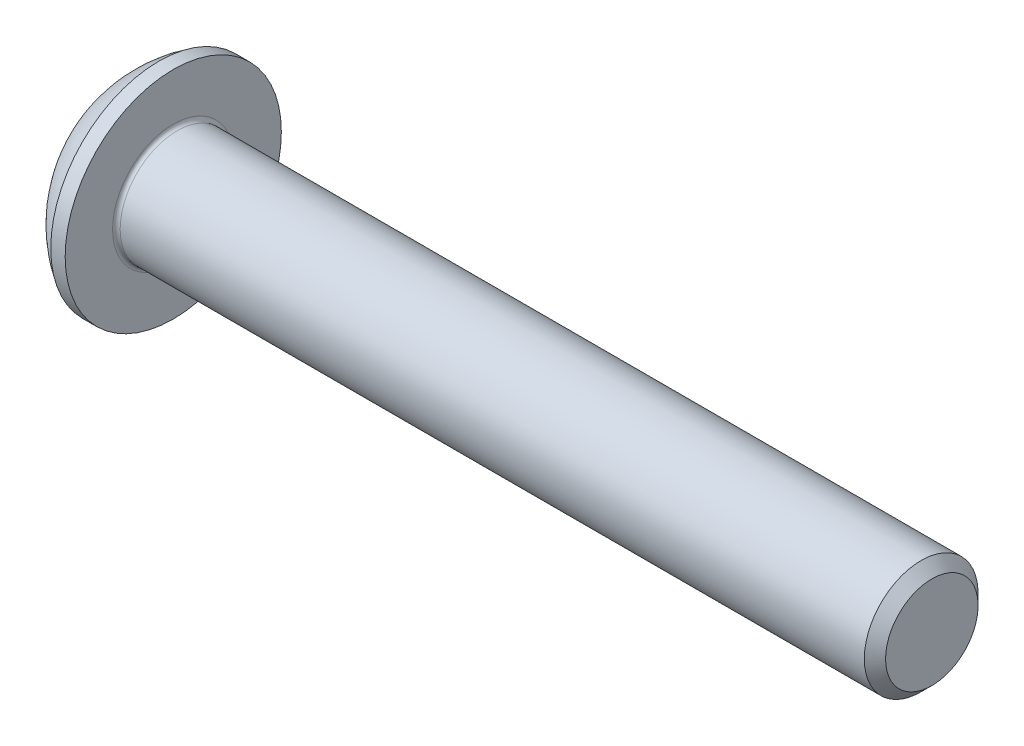
from build123d import *

# Parameters (mm, degrees)
FILLET1_R   = 0.1
HEX_2_DEPTH = 1.04


with BuildPart() as part:
    # BodySke → BaseBody (revolve)
    with BuildSketch(Plane.XY):
        with BuildLine():
            Line((21.65, 0), (21.65, 1.2195))
            Line((21.65, 1.2195), (21.3695, 1.5))
            Line((21.3695, 1.5), (1.65, 1.5))
            Line((1.65, 1.5), (1.65, 2.85))
            Line((1.65, 2.85), (1.27, 2.85))
            ThreePointArc((1.27, 2.85), (0.53140404, 2.229827628), (0, 1.425))
            Line((0, 1.425), (0, 0))
            Line((0, 0), (21.65, 0))
        make_face()
    revolve(axis=Axis((0, 0, 0), (1, 0, 0)))

    # Fillet1
    fillet1_edges = [part.edges().sort_by_distance(p)[0] for p in [
        (1.65, -1.5, 0),
    ]]
    fillet(fillet1_edges, radius=FILLET1_R)

    # Sketch2 → PreBroach (revolve, cut)
    with BuildSketch(Plane.XY):
        Polygon((0, 1), (1.04, 1), (1.617350269, 0), (0, 0), align=None)
    revolve(axis=Axis((0, 0, 0), (1, 0, 0)), mode=Mode.SUBTRACT)

    # Sketch3 → Hex 2 (cut)
    with BuildSketch(Plane(origin=(0, 0, 0), x_dir=(0, 0, -1), z_dir=(1, 0, 0))):
        Polygon((-1, -0.577350269), (-1, 0.577350269), (0, 1.154700538), (1, 0.577350269), (1, -0.577350269), (0, -1.154700538), align=None)
    extrude(amount=HEX_2_DEPTH, mode=Mode.SUBTRACT)


solid = part.part
